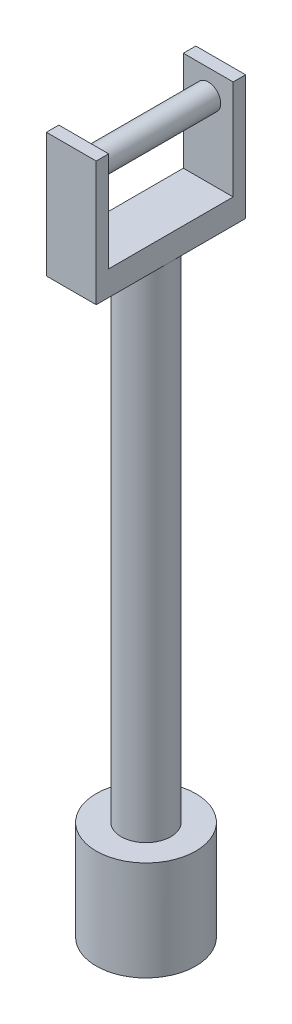
from build123d import *

# Parameters (mm, degrees)
SKETCH2_R           = 25.4
BOSS_EXTRUDE1_DEPTH = 25.4
SKETCH3_R           = 12.7
BOSS_EXTRUDE2_DEPTH = 254
SKETCH4_W           = 25.4
SKETCH4_H           = 76.2
BOSS_EXTRUDE3_DEPTH = 12.7
SKETCH5_W           = 25.4
SKETCH5_H           = 6.35
BOSS_EXTRUDE4_DEPTH = 50.8
SKETCH6_R           = 6.35
BOSS_EXTRUDE5_DEPTH = 69.85
SKETCH7_R           = 25.4
BOSS_EXTRUDE6_DEPTH = 25.4


with BuildPart() as part:
    # Sketch2 → Boss-Extrude1 (new body)
    with BuildSketch(Plane(origin=(0, 0, 0), x_dir=(1, 0, 0), z_dir=(0, 1, 0))):
        Circle(SKETCH2_R)
    extrude(amount=BOSS_EXTRUDE1_DEPTH)

    # Sketch3 → Boss-Extrude2 (add)
    with BuildSketch(Plane(origin=(0, 25.4, 0), x_dir=(1, 0, 0), z_dir=(0, 1, 0))):
        Circle(SKETCH3_R)
    extrude(amount=BOSS_EXTRUDE2_DEPTH)

    # Sketch4 → Boss-Extrude3 (add)
    with BuildSketch(Plane(origin=(0, 279.4, 0), x_dir=(1, 0, 0), z_dir=(0, 1, 0))):
        Rectangle(SKETCH4_W, SKETCH4_H)
    extrude(amount=BOSS_EXTRUDE3_DEPTH)

    # Sketch5 → Boss-Extrude4 (add)
    with BuildSketch(Plane(origin=(0, 292.1, 0), x_dir=(1, 0, 0), z_dir=(0, 1, 0))):
        with Locations((0, 34.925)):
            Rectangle(SKETCH5_W, SKETCH5_H)
        with Locations((0, -34.925)):
            Rectangle(SKETCH5_W, SKETCH5_H)
    extrude(amount=BOSS_EXTRUDE4_DEPTH)

    # Sketch6 → Boss-Extrude5 (add)
    with BuildSketch(Plane.XY.offset(38.1)):
        with Locations((0, 330.2)):
            Circle(SKETCH6_R)
    extrude(amount=-BOSS_EXTRUDE5_DEPTH)

    # Sketch7 → Boss-Extrude6 (add)
    with BuildSketch(Plane.XZ):
        Circle(SKETCH7_R)
    extrude(amount=BOSS_EXTRUDE6_DEPTH)


solid = part.part
